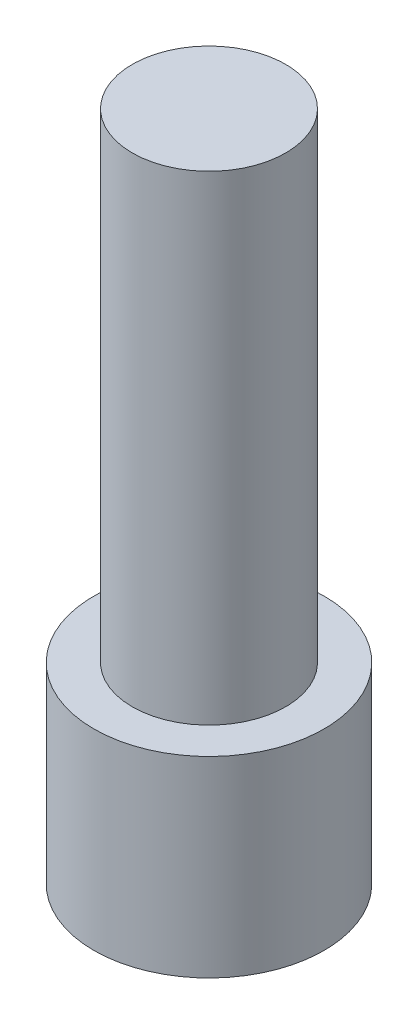
from build123d import *

# Parameters (mm, degrees)
SKETCH1_R           = 4
BOSS_EXTRUDE1_DEPTH = 25
SKETCH2_R           = 6
SKETCH2_R_2         = 4
BOSS_EXTRUDE2_DEPTH = 3
SKETCH3_R           = 6
BOSS_EXTRUDE3_DEPTH = 7


with BuildPart() as part:
    # Sketch1 → Boss-Extrude1 (new body)
    with BuildSketch(Plane(origin=(0, 0, 0), x_dir=(1, 0, 0), z_dir=(0, 1, 0))):
        Circle(SKETCH1_R)
    extrude(amount=BOSS_EXTRUDE1_DEPTH)

    # Sketch2 → Boss-Extrude2 (add)
    with BuildSketch(Plane.XZ):
        Circle(SKETCH2_R)
        Circle(SKETCH2_R_2, mode=Mode.SUBTRACT)
        Circle(SKETCH2_R_2)
        Circle(SKETCH2_R_2)
    extrude(amount=BOSS_EXTRUDE2_DEPTH)

    # Sketch3 → Boss-Extrude3 (add)
    with BuildSketch(Plane.XZ.offset(3)):
        Circle(SKETCH3_R)
        Polygon((4.618802154, 0), (2.309401077, 4), (-2.309401077, 4), (-4.618802154, 0), (-2.309401077, -4), (2.309401077, -4), align=None, mode=Mode.SUBTRACT)
    extrude(amount=BOSS_EXTRUDE3_DEPTH)


solid = part.part
